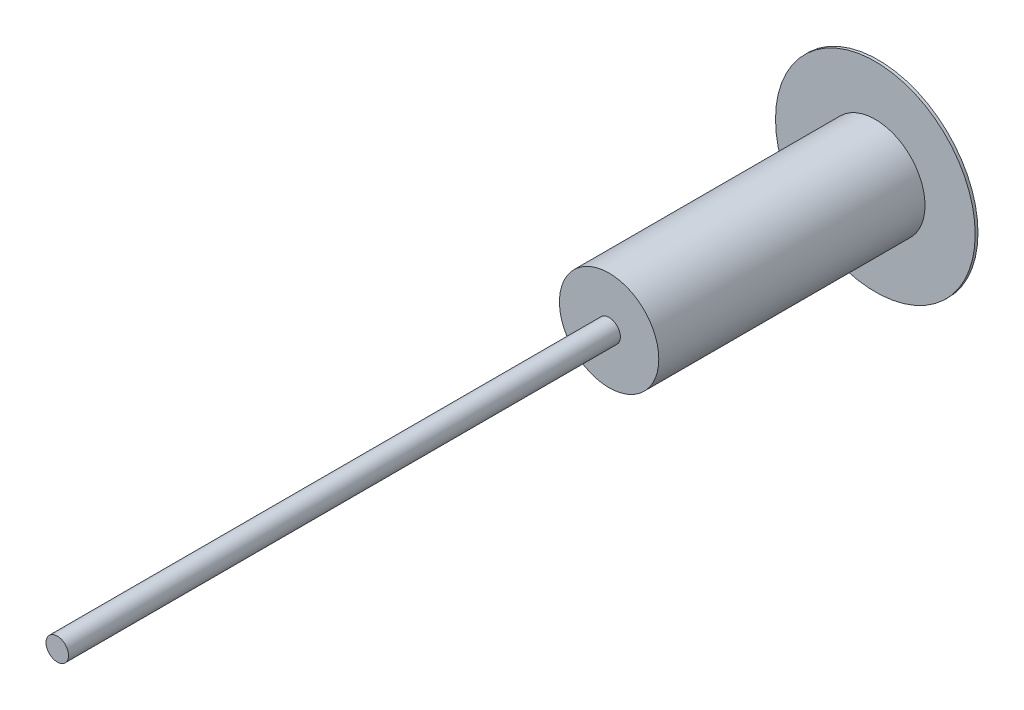
from build123d import *

# Parameters (mm, degrees)
SKETCH1_R                = 50.8
BOSS_EXTRUDE1_DEPTH      = 1650
BOSS_EXTRUDE1_DEPTH_BACK = 2050
SKETCH2_R                = 450
BOSS_EXTRUDE2_DEPTH      = 12.7
SKETCH3_R                = 223.901
BOSS_EXTRUDE3_DEPTH      = 1200


with BuildPart() as part:
    # Sketch1 → Boss-Extrude1 (new body, two sides)
    with BuildSketch(Plane.XY) as boss_extrude1_sk:
        Circle(SKETCH1_R)
    extrude(amount=BOSS_EXTRUDE1_DEPTH)
    extrude(boss_extrude1_sk.sketch, amount=-BOSS_EXTRUDE1_DEPTH_BACK)

    # Sketch2 → Boss-Extrude2 (add)
    with BuildSketch(Plane.XY.offset(-2050)):
        Circle(SKETCH2_R)
    extrude(amount=BOSS_EXTRUDE2_DEPTH)

    # Sketch3 → Boss-Extrude3 (add)
    with BuildSketch(Plane.XY.offset(-2037.3)):
        Circle(SKETCH3_R)
    extrude(amount=BOSS_EXTRUDE3_DEPTH)


solid = part.part
